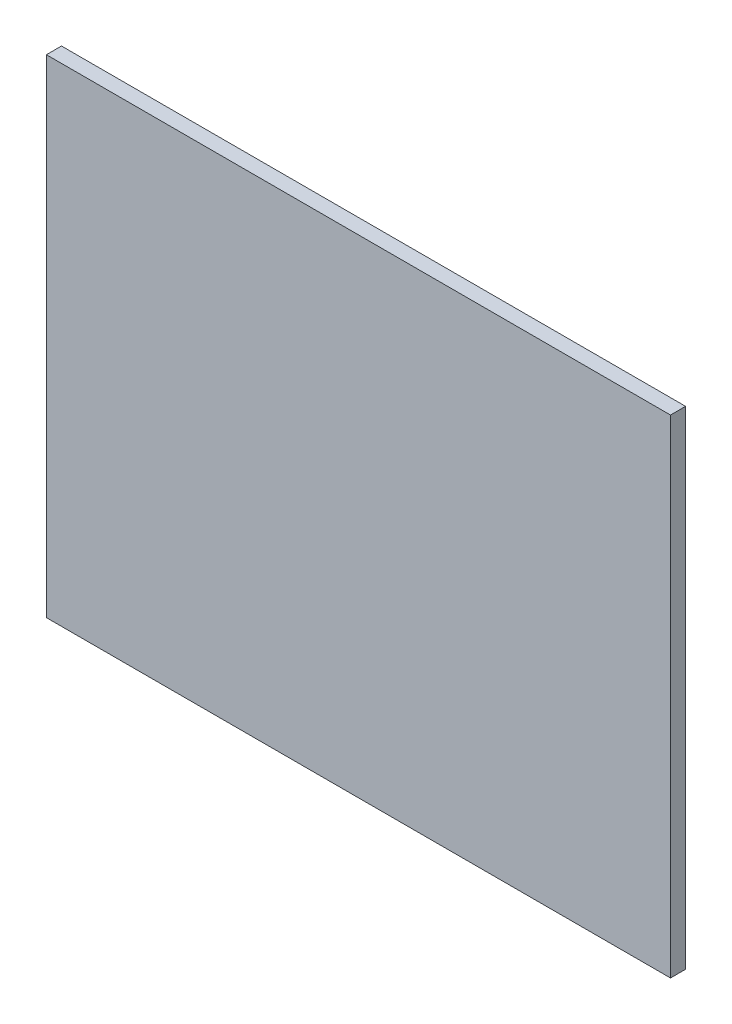
from build123d import *

# Parameters (mm, degrees)
SKETCH1_W           = 745
SKETCH1_H           = 582
BOSS_EXTRUDE1_DEPTH = 18


with BuildPart() as part:
    # Sketch1 → Boss-Extrude1 (new body)
    with BuildSketch(Plane.XY):
        Rectangle(SKETCH1_W, SKETCH1_H)
    extrude(amount=BOSS_EXTRUDE1_DEPTH)


solid = part.part
